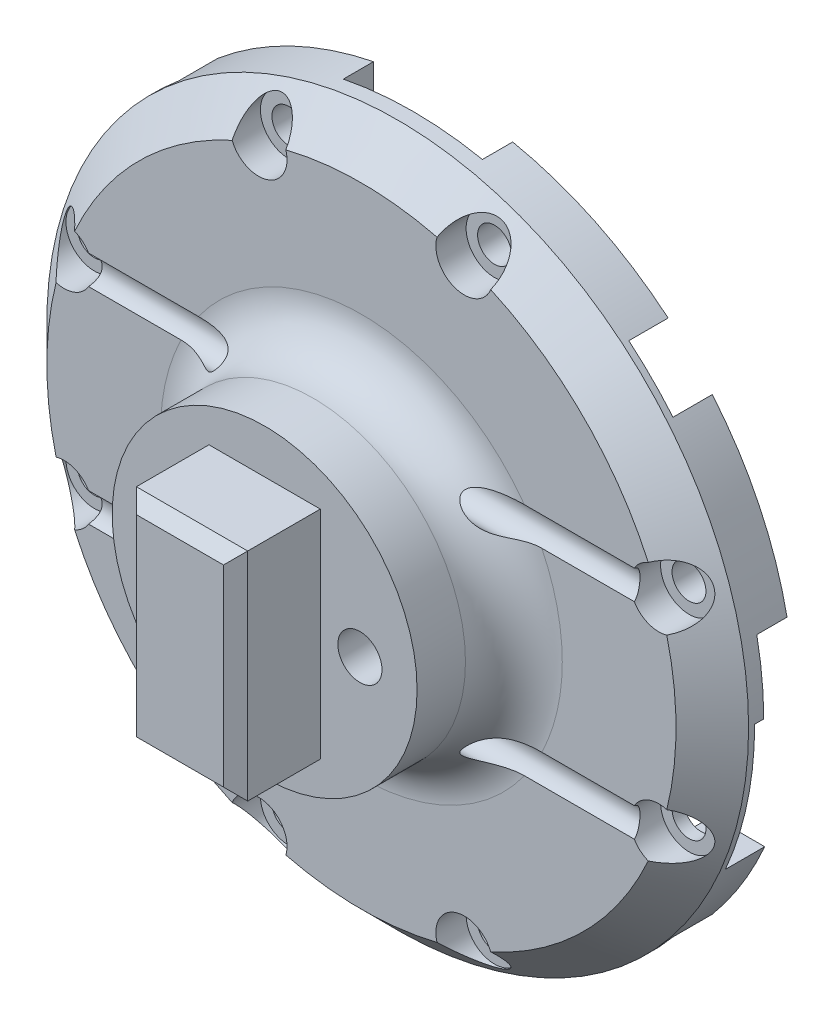
from build123d import *

# Parameters (mm, degrees)
SKETCH1_R               = 29
BOSS_EXTRUDE1_DEPTH     = 6.75
SKETCH3_W               = 44.5
SKETCH3_H               = 44.5
CUT_EXTRUDE1_DEPTH      = 3.25
SKETCH4_R               = 12.6
BOSS_EXTRUDE2_DEPTH     = 8
FILLET1_R               = 4
SKETCH5_R               = 1.825
CUT_EXTRUDE2_DEPTH      = 15.75
SKETCH6_W               = 9.2
SKETCH6_H               = 17.9
BOSS_EXTRUDE3_DEPTH     = 7
CHAMFER1_SIZE           = 1
SKETCH7_R               = 3.25
CUT_EXTRUDE3_DEPTH      = 2.5
FILLET2_R               = 1.5
CHAMFER2_SIZE           = 3
SKETCH9_R               = 1.3
CUT_EXTRUDE5_DEPTH      = 30
CUT_EXTRUDE5_DEPTH_BACK = 30
SKETCH10_W              = 11.5
SKETCH10_H              = 12.03351403
SKETCH10_W_2            = 12.03351403
SKETCH10_H_2            = 11.5
CUT_EXTRUDE6_DEPTH      = 2.5
SKETCH11_R              = 1.4
CUT_EXTRUDE7_DEPTH      = 22.75
SKETCH12_R              = 2.35
CUT_EXTRUDE8_DEPTH      = 2.5
SKETCH13_W              = 6.5
SKETCH13_H              = 6.5
CUT_EXTRUDE9_DEPTH      = 2.25
CHAMFER5_SIZE           = 1
SKETCH14_W              = 15.887507813
SKETCH14_H              = 11.6
CUT_EXTRUDE10_DEPTH     = 3.25


with BuildPart() as part:
    # Sketch1 → Boss-Extrude1 (new body)
    with BuildSketch(Plane.XY):
        Circle(SKETCH1_R)
    extrude(amount=BOSS_EXTRUDE1_DEPTH)

    # Sketch3 → Cut-Extrude1 (cut)
    with BuildSketch(Plane(origin=(0, 0, 0), x_dir=(-1, 0, 0), z_dir=(0, 0, -1))):
        Rectangle(SKETCH3_W, SKETCH3_H)
    extrude(amount=-CUT_EXTRUDE1_DEPTH, mode=Mode.SUBTRACT)

    # Sketch4 → Boss-Extrude2 (add)
    with BuildSketch(Plane.XY.offset(6.75)):
        Circle(SKETCH4_R)
    extrude(amount=BOSS_EXTRUDE2_DEPTH)

    # Fillet1
    fillet1_edges = [part.edges().sort_by_distance(p)[0] for p in [
        (-12.6, 0, 6.75),
    ]]
    fillet(fillet1_edges, radius=FILLET1_R)

    # Sketch5 → Cut-Extrude2 (cut, through all)
    with BuildSketch(Plane.XY.offset(14.75)):
        with Locations((-7.875, 0)):
            Circle(SKETCH5_R)
        with Locations((7.875, 0)):
            Circle(SKETCH5_R)
    extrude(amount=-CUT_EXTRUDE2_DEPTH, mode=Mode.SUBTRACT)

    # Sketch6 → Boss-Extrude3 (add)
    with BuildSketch(Plane.XY.offset(14.75)):
        Rectangle(SKETCH6_W, SKETCH6_H)
    extrude(amount=BOSS_EXTRUDE3_DEPTH)

    # Chamfer1
    chamfer1_edges = [part.edges().sort_by_distance(p)[0] for p in [
        (4.6, 0, 21.75),
        (0, 8.95, 21.75),
        (-4.6, 0, 21.75),
        (0, -8.95, 21.75),
    ]]
    chamfer(chamfer1_edges, length=CHAMFER1_SIZE)

    # Sketch7 → Cut-Extrude3 (cut)
    with BuildSketch(Plane(origin=(0, 0, 3.25), x_dir=(-1, 0, 0), z_dir=(0, 0, -1))):
        with Locations((-7.875, 0)):
            Circle(SKETCH7_R)
        with Locations((7.875, 0)):
            Circle(SKETCH7_R)
    extrude(amount=-CUT_EXTRUDE3_DEPTH, mode=Mode.SUBTRACT)

    # Fillet2
    fillet2_edges = [part.edges().sort_by_distance(p)[0] for p in [
        (11.125, 0, 3.25),
        (-4.625, 0, 3.25),
    ]]
    fillet(fillet2_edges, radius=FILLET2_R)

    # Chamfer2
    chamfer2_edges = [part.edges().sort_by_distance(p)[0] for p in [
        (-29, 0, 6.75),
    ]]
    chamfer(chamfer2_edges, length=CHAMFER2_SIZE)

    # Sketch9 → Cut-Extrude5 (cut, two sides)
    with BuildSketch(Plane(origin=(0, 0, 0), x_dir=(0, 0, -1), z_dir=(1, 0, 0))) as cut_extrude5_sk:
        with Locations((-7.25, 8.5)):
            Circle(SKETCH9_R)
        with Locations((-7.25, -8.5)):
            Circle(SKETCH9_R)
    extrude(amount=CUT_EXTRUDE5_DEPTH, mode=Mode.SUBTRACT)
    extrude(cut_extrude5_sk.sketch, amount=-CUT_EXTRUDE5_DEPTH_BACK, mode=Mode.SUBTRACT)

    # Sketch10 → Cut-Extrude6 (cut)
    with BuildSketch(Plane(origin=(0, 0, 0), x_dir=(-1, 0, 0), z_dir=(0, 0, -1))):
        with Locations((0, -28.01742408)):
            Rectangle(SKETCH10_W, SKETCH10_H)
        with Locations((28.01742408, 0)):
            Rectangle(SKETCH10_W_2, SKETCH10_H_2)
        with Locations((-28.01742408, 0)):
            Rectangle(SKETCH10_W_2, SKETCH10_H_2)
        with Locations((0, 28.01742408)):
            Rectangle(SKETCH10_W, SKETCH10_H)
    extrude(amount=-CUT_EXTRUDE6_DEPTH, mode=Mode.SUBTRACT)

    # Sketch11 → Cut-Extrude7 (cut, through all)
    with BuildSketch(Plane(origin=(0, 0, 0), x_dir=(-1, 0, 0), z_dir=(0, 0, -1))):
        with Locations((-24.571324751, 8.5)):
            Circle(SKETCH11_R)
        with Locations((-24.571324751, -8.5)):
            Circle(SKETCH11_R)
        with Locations((-8.5, 24.571324751)):
            Circle(SKETCH11_R)
        with Locations((8.5, 24.571324751)):
            Circle(SKETCH11_R)
        with Locations((24.571324751, 8.5)):
            Circle(SKETCH11_R)
        with Locations((24.571324751, -8.5)):
            Circle(SKETCH11_R)
        with Locations((8.5, -24.571324751)):
            Circle(SKETCH11_R)
        with Locations((-8.5, -24.571324751)):
            Circle(SKETCH11_R)
    extrude(amount=-CUT_EXTRUDE7_DEPTH, mode=Mode.SUBTRACT)

    # Sketch12 → Cut-Extrude8 (cut)
    with BuildSketch(Plane.XY.offset(6.75)):
        with Locations((-24.571324751, 8.5)):
            Circle(SKETCH12_R)
        with Locations((-24.571324751, -8.5)):
            Circle(SKETCH12_R)
        with Locations((8.5, 24.571324751)):
            Circle(SKETCH12_R)
        with Locations((-8.5, 24.571324751)):
            Circle(SKETCH12_R)
        with Locations((24.571324751, -8.5)):
            Circle(SKETCH12_R)
        with Locations((24.571324751, 8.5)):
            Circle(SKETCH12_R)
        with Locations((-8.5, -24.571324751)):
            Circle(SKETCH12_R)
        with Locations((8.5, -24.571324751)):
            Circle(SKETCH12_R)
    extrude(amount=-CUT_EXTRUDE8_DEPTH, mode=Mode.SUBTRACT)

    # Sketch13 → Cut-Extrude9 (cut)
    with BuildSketch(Plane(origin=(0, 0, 3.25), x_dir=(-1, 0, 0), z_dir=(0, 0, -1))):
        with Locations((-18.9, 11.5)):
            Rectangle(SKETCH13_W, SKETCH13_H)
        with Locations((11.5, 18.9)):
            Rectangle(SKETCH13_W, SKETCH13_H)
        with Locations((18.9, -11.5)):
            Rectangle(SKETCH13_W, SKETCH13_H)
        with Locations((-11.5, -18.9)):
            Rectangle(SKETCH13_W, SKETCH13_H)
    extrude(amount=-CUT_EXTRUDE9_DEPTH, mode=Mode.SUBTRACT)

    # Chamfer5
    chamfer5_edges = [part.edges().sort_by_distance(p)[0] for p in [
        (18.9, 8.25, 3.25),
        (15.65, 11.5, 3.25),
        (18.9, 14.75, 3.25),
        (-8.25, 18.9, 3.25),
        (-11.5, 15.65, 3.25),
        (-14.75, 18.9, 3.25),
        (-18.9, -8.25, 3.25),
        (-15.65, -11.5, 3.25),
        (-18.9, -14.75, 3.25),
        (8.25, -18.9, 3.25),
        (11.5, -15.65, 3.25),
        (14.75, -18.9, 3.25),
    ]]
    chamfer(chamfer5_edges, length=CHAMFER5_SIZE)

    # Sketch14 → Cut-Extrude10 (cut)
    with BuildSketch(Plane(origin=(0, 0, 0), x_dir=(-1, 0, 0), z_dir=(0, 0, -1))):
        with Locations((-27.176000206, -5.8)):
            Rectangle(SKETCH14_W, SKETCH14_H)
    extrude(amount=-CUT_EXTRUDE10_DEPTH, mode=Mode.SUBTRACT)


solid = part.part
